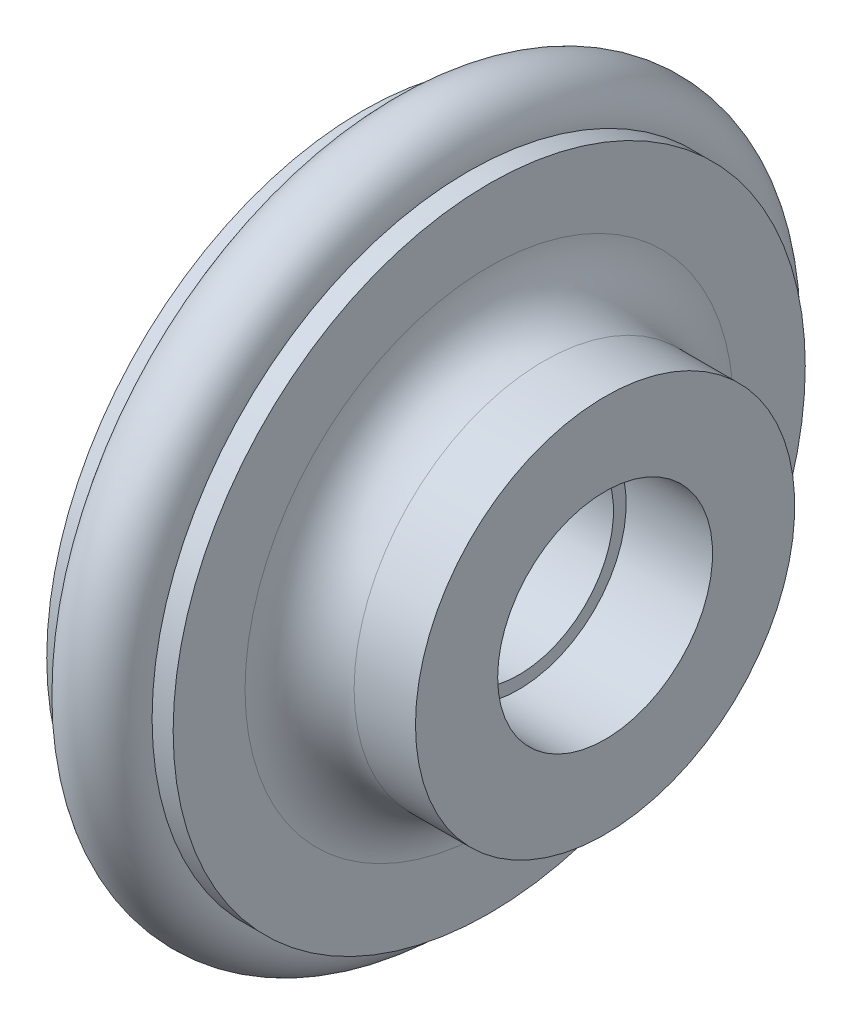
from build123d import *

# Parameters (mm, degrees)
SKETCH_1_R = 1.95


with BuildPart() as part:
    # 草图1 → 旋转1 (revolve)
    with BuildSketch(Plane.XY):
        with Locations((0, 15)):
            Circle(SKETCH_1_R)
        with BuildLine():
            Line((2, 15), (3, 15))
            Line((3, 15), (3, 11.587964483))
            ThreePointArc((3, 11.587964483), (3.757997248, 9.757997248), (5.587964483, 9))
            Line((5.587964483, 9), (8.5, 9))
            Line((8.5, 9), (8.5, 5.1))
            Line((8.5, 5.1), (4.4, 5.1))
            Line((4.4, 5.1), (4.4, 4.5))
            Line((4.4, 4.5), (1.1, 4.5))
            Line((1.1, 4.5), (1.1, 5.1))
            Line((1.1, 5.1), (-3, 5.1))
            Line((-3, 5.1), (-3, 15))
            Line((-3, 15), (-2, 15))
            ThreePointArc((-2, 15), (0, 13), (2, 15))
        make_face()
    revolve(axis=Axis((0, 0, 0), (1, 0, 0)))


solid = part.part
